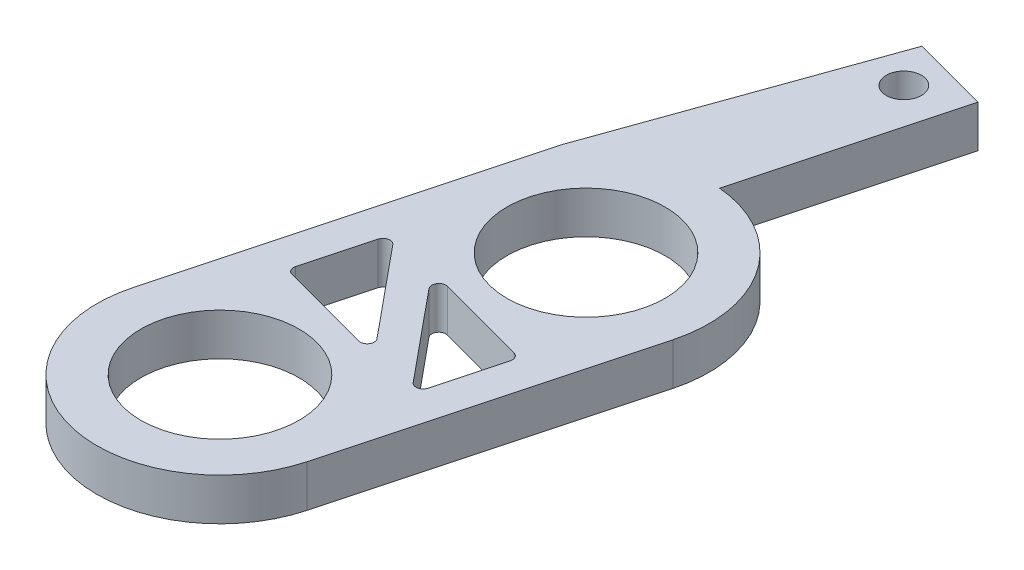
from build123d import *

# Parameters (mm, degrees)
SKETCH1_R           = 14.2875
BOSS_EXTRUDE1_DEPTH = 7.62
CUT_EXTRUDE1_DEPTH  = 8.62
FILLET1_R           = 1.27
SKETCH3_R           = 3.175
CUT_EXTRUDE2_DEPTH  = 7.62


with BuildPart() as part:
    # Sketch1 → Boss-Extrude1 (new body)
    with BuildSketch(Plane(origin=(0, 0, 0), x_dir=(1, 0, 0), z_dir=(0, 1, 0))):
        with BuildLine():
            Line((7.49794353, -57.888099751), (21.467701489, -5.752253277))
            ThreePointArc((21.467701489, -5.752253277), (18.22000551, 12.727215887), (1.986922694, 22.136006036))
            Line((1.986922694, 22.136006036), (11.847928312, 58.937780017))
            Line((11.847928312, 58.937780017), (-1.952736931, 62.635657124))
            Line((-1.952736931, 62.635657124), (-19.044132712, 14.797135091))
            Line((-19.044132712, 14.797135091), (-35.437459449, -46.383593197))
            ThreePointArc((-35.437459449, -46.383593197), (-19.722011237, -73.603547963), (7.49794353, -57.888099751))
        make_face()
        with Locations((-13.969757959, -52.135846474)):
            Circle(SKETCH1_R, mode=Mode.SUBTRACT)
        Circle(SKETCH1_R, mode=Mode.SUBTRACT)
    extrude(amount=BOSS_EXTRUDE1_DEPTH)

    # Sketch2 → Cut-Extrude1 (cut, through all)
    with BuildSketch(Plane(origin=(0, 7.62, 0), x_dir=(1, 0, 0), z_dir=(0, 1, 0))):
        Polygon((-20.265778136, -14.291812351), (-2.906828988, -35.378138121), (-24.374530477, -29.625884844), align=None)
        Polygon((-11.064131806, -16.757386054), (10.403569683, -22.509639332), (6.294817342, -37.843711824), align=None)
    extrude(amount=-CUT_EXTRUDE1_DEPTH, mode=Mode.SUBTRACT)

    # Fillet1
    fillet1_edges = [part.edges().sort_by_distance(p)[0] for p in [
        (-24.374530477, 3.81, 29.625884844),
        (-20.265778136, 3.81, 14.291812351),
        (-2.906828988, 3.81, 35.378138121),
        (6.294817342, 3.81, 37.843711824),
        (-11.064131806, 3.81, 16.757386054),
        (10.403569683, 3.81, 22.509639332),
    ]]
    fillet(fillet1_edges, radius=FILLET1_R)

    # Sketch3 → Cut-Extrude2 (cut)
    with BuildSketch(Plane(origin=(0, 7.62, 0), x_dir=(1, 0, 0), z_dir=(0, 1, 0))):
        with Locations((2.537391129, 54.858527191)):
            Circle(SKETCH3_R)
    extrude(amount=-CUT_EXTRUDE2_DEPTH, mode=Mode.SUBTRACT)


solid = part.part
